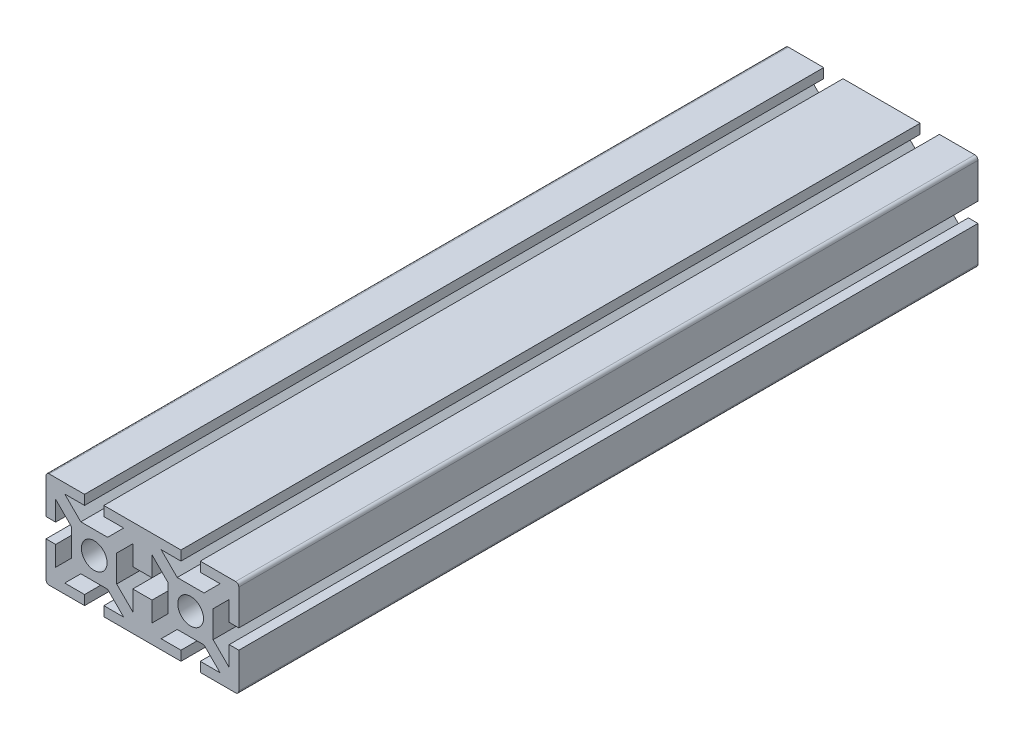
from build123d import *

# Parameters (mm, degrees)
SALIENTE_EXTRUIR1_DEPTH = 115
REDONDEO1_R             = 1


with BuildPart() as part:
    # Croquis1 → Saliente-Extruir1 (new body, symmetric)
    with BuildSketch(Plane.XY):
        Polygon((-4.171572875, 7), (4.171572875, 7), (9.171572875, 12), (3, 12), (3, 15), (27, 15), (27, 12), (20.828427125, 12), (25.828427125, 7), (34.171572875, 7), (39.171572875, 12), (33, 12), (33, 15), (45, 15), (45, 3), (42, 3), (42, 9.171572875), (37, 4.171572875), (37, -4.171572875), (42, -9.171572875), (42, -3), (45, -3), (45, -15), (33, -15), (33, -12), (39.171572875, -12), (34.171572875, -7), (25.828427125, -7), (20.828427125, -12), (27, -12), (27, -15), (3, -15), (3, -12), (9.171572875, -12), (4.171572875, -7), (-4.171572875, -7), (-9.171572875, -12), (-3, -12), (-3, -15), (-15, -15), (-15, -3), (-12, -3), (-12, -9.171572875), (-7, -4.171572875), (-7, 4.171572875), (-12, 9.171572875), (-12, 3), (-15, 3), (-15, 15), (-3, 15), (-3, 12), (-9.171572875, 12), align=None)
        Polygon((7, 4.171572875), (7, -4.171572875), (12, -9.171572875), (12, -3), (18, -3), (18, -9.171572875), (23, -4.171572875), (23, 4.171572875), (18, 9.171572875), (18, 3), (12, 3), (12, 9.171572875), align=None, mode=Mode.SUBTRACT)
        with BuildLine():
            ThreePointArc((2.828427125, 2.828427125), (0, 4), (-2.828427125, 2.828427125))
            ThreePointArc((-2.828427125, 2.828427125), (-4, 0), (-2.828427125, -2.828427125))
            ThreePointArc((-2.828427125, -2.828427125), (0, -4), (2.828427125, -2.828427125))
            ThreePointArc((2.828427125, -2.828427125), (4, 0), (2.828427125, 2.828427125))
        make_face(mode=Mode.SUBTRACT)
        with BuildLine():
            ThreePointArc((32.828427125, 2.828427125), (34, 0), (32.828427125, -2.828427125))
            ThreePointArc((32.828427125, -2.828427125), (30, -4), (27.171572875, -2.828427125))
            ThreePointArc((27.171572875, -2.828427125), (26, 0), (27.171572875, 2.828427125))
            ThreePointArc((27.171572875, 2.828427125), (30, 4), (32.828427125, 2.828427125))
        make_face(mode=Mode.SUBTRACT)
    extrude(amount=SALIENTE_EXTRUIR1_DEPTH, both=True)

    # Redondeo1
    redondeo1_edges = [part.edges().sort_by_distance(p)[0] for p in [
        (-15, 15, 0),
        (45, 15, 0),
        (45, -15, 0),
        (-15, -15, 0),
    ]]
    fillet(redondeo1_edges, radius=REDONDEO1_R)


solid = part.part
